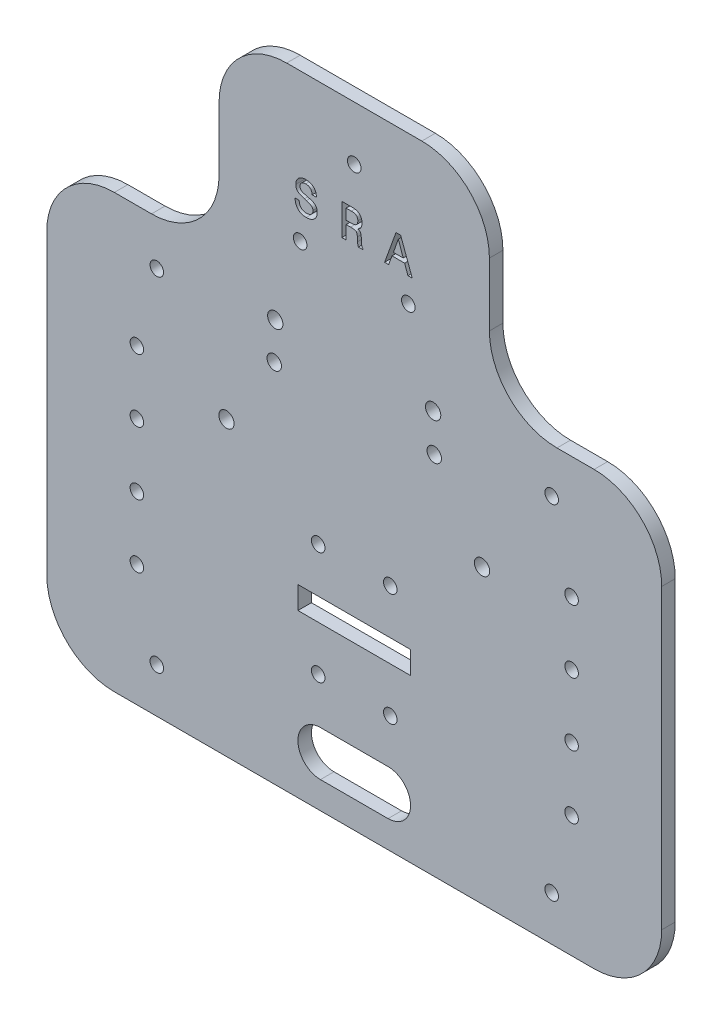
from build123d import *

# Parameters (mm, degrees)
MODEL_R             = 1.5
MODEL_W             = 25
MODEL_H             = 5
MODEL_R_2           = 1.7
BOSS_EXTRUDE1_DEPTH = 3
CUT_EXTRUDE1_DEPTH  = 4
SKETCH6_R           = 1.6
CUT_EXTRUDE2_DEPTH  = 10


with BuildPart() as part:
    # Model → Boss-Extrude1 (new body)
    with BuildSketch(Plane.XY):
        with BuildLine():
            Line((906.194636851, 1018.1431403), (906.194636851, 1084.1431403))
            ThreePointArc((906.194636851, 1084.1431403), (901.801238569, 1094.749742018), (891.194636851, 1099.1431403))
            Line((891.194636851, 1099.1431403), (882.944636851, 1099.1431403))
            ThreePointArc((882.944636851, 1099.1431403), (872.338035133, 1103.536538582), (867.944636851, 1114.1431403))
            Line((867.944636851, 1114.1431403), (867.944636851, 1128.1431403))
            ThreePointArc((867.944636851, 1128.1431403), (863.551238569, 1138.749742018), (852.944636851, 1143.1431403))
            Line((852.944636851, 1143.1431403), (822.944636851, 1143.1431403))
            ThreePointArc((822.944636851, 1143.1431403), (812.338035133, 1138.749742018), (807.944636851, 1128.1431403))
            Line((807.944636851, 1128.1431403), (807.944636851, 1114.1431403))
            ThreePointArc((807.944636851, 1114.1431403), (803.551238569, 1103.536538582), (792.944636851, 1099.1431403))
            Line((792.944636851, 1099.1431403), (784.694636851, 1099.1431403))
            ThreePointArc((784.694636851, 1099.1431403), (774.088035133, 1094.749742018), (769.694636851, 1084.1431403))
            Line((769.694636851, 1084.1431403), (769.694636851, 1018.1431403))
            ThreePointArc((769.694636851, 1018.1431403), (774.088035133, 1007.536538582), (784.694636851, 1003.1431403))
            Line((784.694636851, 1003.1431403), (891.194636851, 1003.1431403))
            ThreePointArc((891.194636851, 1003.1431403), (901.801238569, 1007.536538582), (906.194636851, 1018.1431403))
        make_face()
        with Locations((794.119636851, 1013.0631403)):
            Circle(MODEL_R, mode=Mode.SUBTRACT)
        with Locations((789.694636851, 1030.1431403)):
            Circle(MODEL_R, mode=Mode.SUBTRACT)
        with BuildLine():
            Line((830.444636851, 1019.1431403), (845.444636851, 1019.1431403))
            ThreePointArc((845.444636851, 1019.1431403), (850.444636851, 1014.1431403), (845.444636851, 1009.1431403))
            Line((845.444636851, 1009.1431403), (830.444636851, 1009.1431403))
            ThreePointArc((830.444636851, 1009.1431403), (825.444636851, 1014.1431403), (830.444636851, 1019.1431403))
        make_face(mode=Mode.SUBTRACT)
        with Locations((829.944636851, 1029.1431403)):
            Circle(MODEL_R, mode=Mode.SUBTRACT)
        with Locations((789.694636851, 1044.1431403)):
            Circle(MODEL_R, mode=Mode.SUBTRACT)
        with Locations((789.694636851, 1058.1431403)):
            Circle(MODEL_R, mode=Mode.SUBTRACT)
        with Locations((789.694636851, 1072.1431403)):
            Circle(MODEL_R, mode=Mode.SUBTRACT)
        with Locations((837.944636851, 1041.6431403)):
            Rectangle(MODEL_W, MODEL_H, mode=Mode.SUBTRACT)
        with Locations((829.944636851, 1054.1431403)):
            Circle(MODEL_R, mode=Mode.SUBTRACT)
        with Locations((809.579636851, 1067.95000384)):
            Circle(MODEL_R_2, mode=Mode.SUBTRACT)
        with Locations((845.944636851, 1029.1431403)):
            Circle(MODEL_R, mode=Mode.SUBTRACT)
        with Locations((881.769636851, 1013.0631403)):
            Circle(MODEL_R, mode=Mode.SUBTRACT)
        with Locations((886.194636851, 1030.1431403)):
            Circle(MODEL_R, mode=Mode.SUBTRACT)
        with Locations((845.944636851, 1054.1431403)):
            Circle(MODEL_R, mode=Mode.SUBTRACT)
        with Locations((866.309636402, 1067.95000384)):
            Circle(MODEL_R_2, mode=Mode.SUBTRACT)
        with Locations((886.194636851, 1044.1431403)):
            Circle(MODEL_R, mode=Mode.SUBTRACT)
        with Locations((886.194636851, 1058.1431403)):
            Circle(MODEL_R, mode=Mode.SUBTRACT)
        with Locations((886.194636851, 1072.1431403)):
            Circle(MODEL_R, mode=Mode.SUBTRACT)
        with Locations((794.119636851, 1089.2131403)):
            Circle(MODEL_R, mode=Mode.SUBTRACT)
        with Locations((820.413124926, 1092.508782294)):
            Circle(MODEL_R_2, mode=Mode.SUBTRACT)
        with Locations((825.944636851, 1110.358530609)):
            Circle(MODEL_R, mode=Mode.SUBTRACT)
        with Locations((837.944636851, 1131.1431403)):
            Circle(MODEL_R, mode=Mode.SUBTRACT)
        with Locations((855.454630559, 1092.508782294)):
            Circle(MODEL_R_2, mode=Mode.SUBTRACT)
        with Locations((881.769636851, 1089.28763399)):
            Circle(MODEL_R, mode=Mode.SUBTRACT)
        with Locations((849.944636851, 1110.358530609)):
            Circle(MODEL_R, mode=Mode.SUBTRACT)
    extrude(amount=BOSS_EXTRUDE1_DEPTH)

    # Sketch4 → Cut-Extrude1 (cut, through all)
    with BuildSketch(Plane.XY.offset(3)):
        with BuildLine():
            add(Edge.make_bspline(
                [(825.725792512, 1118.129759801), (825.727231967, 1118.067272118), (825.730051752, 1117.944863445), (825.750697214, 1117.766688984), (825.78342857, 1117.597783288), (825.832238614, 1117.439900767), (825.890507945, 1117.289741876), (825.967477207, 1117.152319712), (826.054353994, 1117.022735701), (826.156526122, 1116.905613809), (826.269151819, 1116.799725784), (826.391882231, 1116.707773545), (826.523900825, 1116.629394179), (826.666458618, 1116.568149717), (826.817428232, 1116.518137369), (826.977218661, 1116.481535597), (827.147102934, 1116.461648182), (827.263221341, 1116.458749538), (827.322795233, 1116.457262405)],
                knots=[0, 0, 0, 0, 0.000187425, 0.000367152, 0.000537418, 0.00070276, 0.000862361, 0.001019594, 0.001174225, 0.001329651, 0.001484752, 0.001637193, 0.00178883, 0.001944202, 0.002101676, 0.002265449, 0.002435082, 0.002613804, 0.002613804, 0.002613804, 0.002613804], degree=3))
            add(Edge.make_bspline(
                [(827.322795233, 1116.457262405), (827.377046486, 1116.458390022), (827.482885511, 1116.460589895), (827.637548819, 1116.477379204), (827.784369642, 1116.501634658), (827.921486525, 1116.542733279), (828.051909875, 1116.589699177), (828.173504541, 1116.649190533), (828.286897699, 1116.719695499), (828.390690899, 1116.800803676), (828.485372793, 1116.890109254), (828.566538223, 1116.988344874), (828.637884204, 1117.091922344), (828.693992075, 1117.204086734), (828.738103622, 1117.323422661), (828.769733116, 1117.449444074), (828.789234865, 1117.582781473), (828.791089767, 1117.673820038), (828.792037737, 1117.720346376)],
                knots=[0, 0, 0, 0, 0.000162708, 0.000317427, 0.000466371, 0.000608361, 0.000746169, 0.000881873, 0.001013606, 0.001146032, 0.001276446, 0.00140322, 0.001527646, 0.001652957, 0.001778361, 0.001908646, 0.002042103, 0.002181598, 0.002181598, 0.002181598, 0.002181598], degree=3))
            add(Edge.make_bspline(
                [(828.792037737, 1117.720346376), (828.791018778, 1117.752384851), (828.789011502, 1117.815498324), (828.770018046, 1117.908316196), (828.743370263, 1117.998444711), (828.703012007, 1118.08571311), (828.650882443, 1118.169253272), (828.58697518, 1118.24942743), (828.515017317, 1118.329124234), (828.427651608, 1118.4017736), (828.332330956, 1118.475862778), (828.22278374, 1118.542815491), (828.103236671, 1118.607921291), (827.973839747, 1118.672946439), (827.831185099, 1118.731578751), (827.677250938, 1118.787437165), (827.513295002, 1118.843819999), (827.398957753, 1118.875625562), (827.340217081, 1118.891965645)],
                knots=[0, 0, 0, 0, 9.5996e-05, 0.000189105, 0.00028325, 0.000377451, 0.000476558, 0.000577915, 0.00068476, 0.000797983, 0.000918195, 0.001046696, 0.001182494, 0.001326634, 0.001480862, 0.001644841, 0.001817924, 0.002000796, 0.002000796, 0.002000796, 0.002000796], degree=3))
            add(Edge.make_bspline(
                [(827.340217081, 1118.891965645), (827.294780302, 1118.904745959), (827.209340413, 1118.92877822), (827.088287029, 1118.959648448), (826.984285083, 1118.989671753), (826.919708187, 1119.006305609), (826.890152678, 1119.01391858)],
                knots=[0, 0, 0, 0, 0.000141595, 0.000266258, 0.000374747, 0.000466303, 0.000466303, 0.000466303, 0.000466303], degree=3))
            add(Edge.make_bspline(
                [(826.890152678, 1119.01391858), (826.797056352, 1119.040912895), (826.618264299, 1119.092755639), (826.36377633, 1119.176778919), (826.134206863, 1119.262959797), (825.930070353, 1119.353518547), (825.749869953, 1119.444347142), (825.593187648, 1119.536062547), (825.463064246, 1119.632785768), (825.353294584, 1119.731089247), (825.26528415, 1119.83877025), (825.188743773, 1119.952691848), (825.124794119, 1120.077021888), (825.072487424, 1120.211341098), (825.031922042, 1120.355790626), (825.003387747, 1120.509828802), (824.985528847, 1120.673413553), (824.983501911, 1120.78557602), (824.982460336, 1120.843212607)],
                knots=[0, 0, 0, 0, 0.000290774, 0.000558433, 0.000803804, 0.001026098, 0.001228027, 0.001409039, 0.001569903, 0.001713758, 0.001849827, 0.001985927, 0.002124885, 0.002268315, 0.002417683, 0.002574291, 0.002737826, 0.00291069, 0.00291069, 0.00291069, 0.00291069], degree=3))
            add(Edge.make_bspline(
                [(824.982460336, 1120.843212607), (824.984594216, 1120.917332754), (824.988765556, 1121.062223939), (825.016037162, 1121.274007925), (825.064285295, 1121.474387136), (825.131694065, 1121.66378276), (825.21534166, 1121.843923833), (825.320942646, 1122.011552567), (825.445562701, 1122.167849925), (825.587356921, 1122.312633406), (825.74514614, 1122.442934413), (825.916101396, 1122.555934998), (826.096801207, 1122.655051254), (826.291164256, 1122.732718816), (826.496732165, 1122.793969999), (826.713990796, 1122.837058625), (826.942716081, 1122.863793006), (827.099139505, 1122.866909852), (827.179064989, 1122.868502422)],
                knots=[0, 0, 0, 0, 0.000222361, 0.000434674, 0.000639263, 0.000839467, 0.001036898, 0.001233881, 0.001432276, 0.001635552, 0.001840773, 0.002044923, 0.002249547, 0.002457948, 0.002671543, 0.002892206, 0.003121635, 0.003361343, 0.003361343, 0.003361343, 0.003361343], degree=3))
            add(Edge.make_bspline(
                [(827.179064989, 1122.868502422), (827.270123127, 1122.867064143), (827.44736017, 1122.864264653), (827.705062889, 1122.835837152), (827.946922381, 1122.791382223), (828.173333448, 1122.729502206), (828.383943522, 1122.647679862), (828.578931782, 1122.547913341), (828.757558632, 1122.428845026), (828.920995783, 1122.293963529), (829.066309836, 1122.141461085), (829.192014983, 1121.972992072), (829.298418391, 1121.790265895), (829.386459599, 1121.592909503), (829.452493018, 1121.379705896), (829.500093093, 1121.152226033), (829.529669417, 1120.909801018), (829.533433536, 1120.743123529), (829.535369913, 1120.657379563)],
                knots=[0, 0, 0, 0, 0.000273081, 0.00053153, 0.000776698, 0.00101023, 0.001234544, 0.001453365, 0.001665971, 0.001877324, 0.002087838, 0.00229632, 0.002506478, 0.00272096, 0.002943198, 0.003174694, 0.003417439, 0.003674612, 0.003674612, 0.003674612, 0.003674612], degree=3))
            Line((829.535369913, 1120.657379563), (829.535369913, 1120.638505895))
            Line((829.535369913, 1120.638505895), (828.606204693, 1120.638505895))
            add(Edge.make_bspline(
                [(828.606204693, 1120.638505895), (828.600586877, 1120.693272607), (828.589650343, 1120.799890176), (828.562462964, 1120.95443683), (828.523895112, 1121.098690788), (828.479171978, 1121.234371141), (828.419405101, 1121.358258916), (828.353413727, 1121.473896724), (828.27584813, 1121.578567196), (828.189900614, 1121.673566569), (828.09476212, 1121.758560891), (827.990811285, 1121.832639176), (827.877523357, 1121.893298269), (827.757535165, 1121.945494732), (827.628045643, 1121.983311369), (827.49096086, 1122.013497943), (827.344909339, 1122.028584615), (827.244907828, 1122.031009288), (827.193583195, 1122.032253725)],
                knots=[0, 0, 0, 0, 0.000165138, 0.000321483, 0.000470088, 0.000612876, 0.000749263, 0.000881983, 0.001011781, 0.001139227, 0.001265703, 0.001393801, 0.001521139, 0.00165058, 0.001785607, 0.001925133, 0.00207119, 0.002225193, 0.002225193, 0.002225193, 0.002225193], degree=3))
            add(Edge.make_bspline(
                [(827.193583195, 1122.032253725), (827.146105825, 1122.031643521), (827.053334902, 1122.030451182), (826.918196793, 1122.014571119), (826.789714953, 1121.994047774), (826.668653045, 1121.961906257), (826.555408638, 1121.919975825), (826.449736024, 1121.868353132), (826.350806094, 1121.809015981), (826.259585957, 1121.741220239), (826.177667761, 1121.665387038), (826.10681742, 1121.582875868), (826.046152128, 1121.494431214), (825.996554351, 1121.40001532), (825.959073753, 1121.298823118), (825.930862024, 1121.191977677), (825.915305818, 1121.078863886), (825.912864156, 1121.001504546), (825.911625556, 1120.962261901)],
                knots=[0, 0, 0, 0, 0.000142345, 0.000278143, 0.000407746, 0.000532408, 0.000653223, 0.000769451, 0.000884731, 0.000998845, 0.001109793, 0.001218921, 0.001324425, 0.001430924, 0.001537976, 0.001647489, 0.001761852, 0.001879593, 0.001879593, 0.001879593, 0.001879593], degree=3))
            add(Edge.make_bspline(
                [(825.911625556, 1120.962261901), (825.912531948, 1120.923035911), (825.914281774, 1120.847308548), (825.925710367, 1120.737471411), (825.94572312, 1120.635782962), (825.974461411, 1120.542085811), (826.012931919, 1120.457301872), (826.057802086, 1120.37927043), (826.111744806, 1120.309715956), (826.175788099, 1120.244641541), (826.259332696, 1120.185395756), (826.366822215, 1120.128452457), (826.499503507, 1120.068735003), (826.660069187, 1120.010275068), (826.847144745, 1119.949844414), (827.06094323, 1119.887142764), (827.301890871, 1119.825542261), (827.471778979, 1119.785509207), (827.560893821, 1119.76450986)],
                knots=[0, 0, 0, 0, 0.000117678, 0.000227182, 0.000330822, 0.00042817, 0.000520449, 0.000609592, 0.00069758, 0.000783813, 0.000882548, 0.001003398, 0.001148304, 0.001318737, 0.001515698, 0.001738059, 0.001987016, 0.002261683, 0.002261683, 0.002261683, 0.002261683], degree=3))
            add(Edge.make_bspline(
                [(827.560893821, 1119.76450986), (827.666601406, 1119.739188298), (827.869739287, 1119.690527944), (828.158265585, 1119.60770611), (828.418906861, 1119.522212659), (828.651726555, 1119.434781953), (828.856169035, 1119.342021314), (829.032206307, 1119.245390736), (829.181147281, 1119.145541178), (829.303176951, 1119.03874542), (829.404486778, 1118.924394732), (829.48872181, 1118.799172728), (829.561934191, 1118.664451014), (829.619997904, 1118.516469922), (829.666635749, 1118.357723214), (829.69724268, 1118.186318848), (829.718985382, 1118.004494016), (829.720450037, 1117.879149374), (829.721202957, 1117.814714719)],
                knots=[0, 0, 0, 0, 0.000326062, 0.000626593, 0.000900221, 0.001148822, 0.001372308, 0.001573111, 0.001750697, 0.001909125, 0.002058267, 0.002207664, 0.00236096, 0.002517326, 0.002683646, 0.002856486, 0.003039099, 0.003232278, 0.003232278, 0.003232278, 0.003232278], degree=3))
            add(Edge.make_bspline(
                [(829.721202957, 1117.814714719), (829.719296402, 1117.7328434), (829.715570901, 1117.572862971), (829.685162806, 1117.339183523), (829.631844331, 1117.118909681), (829.562235887, 1116.910015673), (829.467344985, 1116.71557281), (829.354805671, 1116.5326115), (829.217493826, 1116.365492242), (829.064189684, 1116.210054541), (828.893241633, 1116.069830651), (828.70385564, 1115.951996157), (828.503553651, 1115.846885699), (828.286580003, 1115.765366614), (828.05677278, 1115.698692389), (827.811317386, 1115.656001837), (827.552502348, 1115.624699303), (827.374680301, 1115.622262096), (827.283596076, 1115.621013707)],
                knots=[0, 0, 0, 0, 0.000245568, 0.000479852, 0.000705221, 0.000924681, 0.001138966, 0.001352877, 0.001567599, 0.001786266, 0.002007114, 0.002229034, 0.002454347, 0.002684602, 0.002923111, 0.003171135, 0.003431185, 0.003704266, 0.003704266, 0.003704266, 0.003704266], degree=3))
            add(Edge.make_bspline(
                [(827.283596076, 1115.621013707), (827.190592326, 1115.62285781), (827.009383635, 1115.626450865), (826.745610594, 1115.657438553), (826.497248482, 1115.707971781), (826.264520221, 1115.778612166), (826.047062679, 1115.870479781), (825.846410131, 1115.984883439), (825.659184043, 1116.116542789), (825.49016582, 1116.27020224), (825.338777673, 1116.442456639), (825.204480362, 1116.631969191), (825.089386013, 1116.839464863), (824.993880524, 1117.064602079), (824.915164595, 1117.306407383), (824.856398952, 1117.565464067), (824.815334455, 1117.841680545), (824.802983997, 1118.031870294), (824.796627292, 1118.129759801)],
                knots=[0, 0, 0, 0, 0.000278935, 0.000543477, 0.000795463, 0.001038403, 0.00127193, 0.00150207, 0.00173008, 0.001957238, 0.002185594, 0.002416812, 0.002652727, 0.002895975, 0.003149409, 0.003414599, 0.003691988, 0.003986175, 0.003986175, 0.003986175, 0.003986175], degree=3))
            Line((824.796627292, 1118.129759801), (825.725792512, 1118.129759801))
        make_face()
        with BuildLine():
            Line((835.205625944, 1115.713930229), (835.205625944, 1122.682669378))
            Line((835.205625944, 1122.682669378), (837.566286331, 1122.682669378))
            add(Edge.make_bspline(
                [(837.566286331, 1122.682669378), (837.649114387, 1122.681635442), (837.81032678, 1122.67962304), (838.044100912, 1122.653731668), (838.263266021, 1122.61547558), (838.467087562, 1122.560618854), (838.655907108, 1122.489318759), (838.829070472, 1122.402085777), (838.988164012, 1122.299967603), (839.130468587, 1122.180362978), (839.25715912, 1122.046467949), (839.368025739, 1121.898459803), (839.458139025, 1121.734197716), (839.537271801, 1121.557889402), (839.593445336, 1121.365086614), (839.63631756, 1121.158886668), (839.660453928, 1120.938150963), (839.663867728, 1120.786162836), (839.665619, 1120.708193286)],
                knots=[0, 0, 0, 0, 0.000248367, 0.00048341, 0.000704683, 0.000915292, 0.001115633, 0.001309117, 0.001495968, 0.001681484, 0.001865315, 0.002047956, 0.00223452, 0.002426303, 0.002626549, 0.002835541, 0.003057593, 0.003291499, 0.003291499, 0.003291499, 0.003291499], degree=3))
            add(Edge.make_bspline(
                [(839.665619, 1120.708193286), (839.662933835, 1120.616553178), (839.657746017, 1120.439501717), (839.615197816, 1120.185346946), (839.545944424, 1119.952334211), (839.446623236, 1119.742158077), (839.320906924, 1119.553172626), (839.166097872, 1119.389521697), (838.985733366, 1119.246911138), (838.848612112, 1119.175340662), (838.778556579, 1119.138775157)],
                knots=[0, 0, 0, 0, 0.000274778, 0.000530879, 0.000770619, 0.001001819, 0.0012257, 0.001448587, 0.001675113, 0.001911737, 0.001911737, 0.001911737, 0.001911737], degree=3))
            add(Edge.make_bspline(
                [(838.778556579, 1119.138775157), (838.836533862, 1119.118477381), (838.947662794, 1119.079571278), (839.094261871, 1118.992133073), (839.217114706, 1118.889771499), (839.296765614, 1118.786383157), (839.347574532, 1118.691961606), (839.381996257, 1118.608649189), (839.413476493, 1118.513554365), (839.441179463, 1118.406393695), (839.464154659, 1118.287089779), (839.482266567, 1118.155173699), (839.498405683, 1118.01140196), (839.506220256, 1117.911530874), (839.510274189, 1117.859721159)],
                knots=[0, 0, 0, 0, 0.000183872, 0.000352439, 0.000508967, 0.000661131, 0.000740385, 0.000830175, 0.000931179, 0.001040693, 0.001161987, 0.001295444, 0.001440059, 0.001595952, 0.001595952, 0.001595952, 0.001595952], degree=3))
            Line((839.510274189, 1117.859721159), (839.581413402, 1116.714234661))
            add(Edge.make_bspline(
                [(839.581413402, 1116.714234661), (839.58568628, 1116.656599293), (839.593678429, 1116.548795961), (839.613038251, 1116.399736983), (839.639451247, 1116.27521594), (839.668451226, 1116.171872874), (839.70921271, 1116.087520909), (839.758294846, 1116.016274407), (839.815927525, 1115.953769861), (839.862838506, 1115.922605643), (839.886295739, 1115.907022376)],
                knots=[0, 0, 0, 0, 0.000173376, 0.000324288, 0.00045043, 0.000555142, 0.0006454, 0.000729968, 0.000814174, 0.000898392, 0.000898392, 0.000898392, 0.000898392], degree=3))
            Line((839.886295739, 1115.907022376), (839.886295739, 1115.713930229))
            Line((839.886295739, 1115.713930229), (838.864213998, 1115.713930229))
            add(Edge.make_bspline(
                [(838.864213998, 1115.713930229), (838.853141737, 1115.735027158), (838.828818651, 1115.781372021), (838.799645093, 1115.860384156), (838.773364051, 1115.953637717), (838.750612522, 1116.061364737), (838.730104696, 1116.186325142), (838.713598033, 1116.330303975), (838.697185452, 1116.493833689), (838.68962291, 1116.609672764), (838.685640057, 1116.670680042)],
                knots=[0, 0, 0, 0, 7.142e-05, 0.000156893, 0.000252018, 0.000361935, 0.000487002, 0.000631785, 0.000796616, 0.000980011, 0.000980011, 0.000980011, 0.000980011], degree=3))
            Line((838.685640057, 1116.670680042), (838.636278155, 1117.582423414))
            add(Edge.make_bspline(
                [(838.636278155, 1117.582423414), (838.632592993, 1117.637173249), (838.625528606, 1117.7421277), (838.604773794, 1117.891810613), (838.579268246, 1118.026708628), (838.547820516, 1118.146956667), (838.508901907, 1118.252266842), (838.462920141, 1118.342736945), (838.410195276, 1118.418103766), (838.349694921, 1118.481586249), (838.272687208, 1118.533027571), (838.174400235, 1118.574005597), (838.054142299, 1118.609595986), (837.910633092, 1118.637567912), (837.744934738, 1118.660861967), (837.55536874, 1118.675651947), (837.342827292, 1118.686252731), (837.193184293, 1118.686912965), (837.114770107, 1118.687258933)],
                knots=[0, 0, 0, 0, 0.000164575, 0.000315488, 0.000453013, 0.000576272, 0.000687912, 0.000789207, 0.000879838, 0.000962998, 0.001050782, 0.001155444, 0.001281293, 0.001426504, 0.001593634, 0.001783045, 0.001996705, 0.002231917, 0.002231917, 0.002231917, 0.002231917], degree=3))
            Line((837.114770107, 1118.687258933), (836.134791164, 1118.687258933))
            Line((836.134791164, 1118.687258933), (836.134791164, 1115.713930229))
            Line((836.134791164, 1115.713930229), (835.205625944, 1115.713930229))
        make_face()
        with BuildLine():
            Line((837.300603151, 1121.846420681), (836.134791164, 1121.846420681))
            Line((836.134791164, 1121.846420681), (836.134791164, 1119.523507631))
            Line((836.134791164, 1119.523507631), (837.235271221, 1119.523507631))
            add(Edge.make_bspline(
                [(837.235271221, 1119.523507631), (837.302569337, 1119.524216792), (837.431978354, 1119.525580454), (837.617938546, 1119.539414418), (837.788933884, 1119.558217416), (837.943462693, 1119.589115809), (838.082866061, 1119.625800277), (838.205406151, 1119.67308083), (838.314345311, 1119.72505075), (838.405840545, 1119.790724845), (838.484633544, 1119.865189097), (838.553574661, 1119.949484724), (838.610190948, 1120.046859837), (838.656435482, 1120.154741727), (838.692714937, 1120.27351954), (838.718940901, 1120.403279032), (838.732542444, 1120.544333257), (838.735122008, 1120.641868175), (838.73645378, 1120.692223259)],
                knots=[0, 0, 0, 0, 0.00020185, 0.000388142, 0.000559217, 0.000717525, 0.00086052, 0.000991023, 0.001111138, 0.001221515, 0.001327299, 0.001435681, 0.00154698, 0.001664029, 0.0017871, 0.001918929, 0.002060502, 0.002211603, 0.002211603, 0.002211603, 0.002211603], degree=3))
            add(Edge.make_bspline(
                [(838.73645378, 1120.692223259), (838.735112295, 1120.742088023), (838.73252762, 1120.838163826), (838.719207718, 1120.97691305), (838.691704196, 1121.104214914), (838.658923343, 1121.221998037), (838.611256931, 1121.327855325), (838.554822231, 1121.422476342), (838.488657393, 1121.507131587), (838.410766948, 1121.580429491), (838.319948886, 1121.643649981), (838.216279963, 1121.698986532), (838.098148554, 1121.744786546), (837.966016475, 1121.782737494), (837.819729752, 1121.811060015), (837.659134645, 1121.830669189), (837.484731352, 1121.844286382), (837.36354386, 1121.845691111), (837.300603151, 1121.846420681)],
                knots=[0, 0, 0, 0, 0.00014965, 0.000288335, 0.000417319, 0.00053997, 0.00065436, 0.000764411, 0.000869846, 0.00097563, 0.001083983, 0.001200897, 0.001327339, 0.001463346, 0.001612827, 0.001773815, 0.001948523, 0.00213731, 0.00213731, 0.00213731, 0.00213731], degree=3))
        make_face(mode=Mode.SUBTRACT)
        Polygon((844.685459377, 1115.713930229), (847.21598278, 1122.682669378), (848.248227267, 1122.682669378), (850.817949828, 1115.713930229), (849.868459119, 1115.713930229), (849.128030584, 1117.758093713), (846.326016718, 1117.758093713), (845.584136363, 1115.713930229), align=None)
        Polygon((846.646869083, 1118.594342411), (848.815889143, 1118.594342411), (847.729927292, 1121.679461305), align=None, mode=Mode.SUBTRACT)
    extrude(amount=-CUT_EXTRUDE1_DEPTH, mode=Mode.SUBTRACT)

    # Sketch6 → Cut-Extrude2 (cut)
    with BuildSketch(Plane.XY.offset(3)):
        with Locations((820.189636851, 1084.26000384)):
            Circle(SKETCH6_R)
        with Locations((855.699636402, 1084.26000384)):
            Circle(SKETCH6_R)
    extrude(amount=-CUT_EXTRUDE2_DEPTH, mode=Mode.SUBTRACT)


solid = part.part
